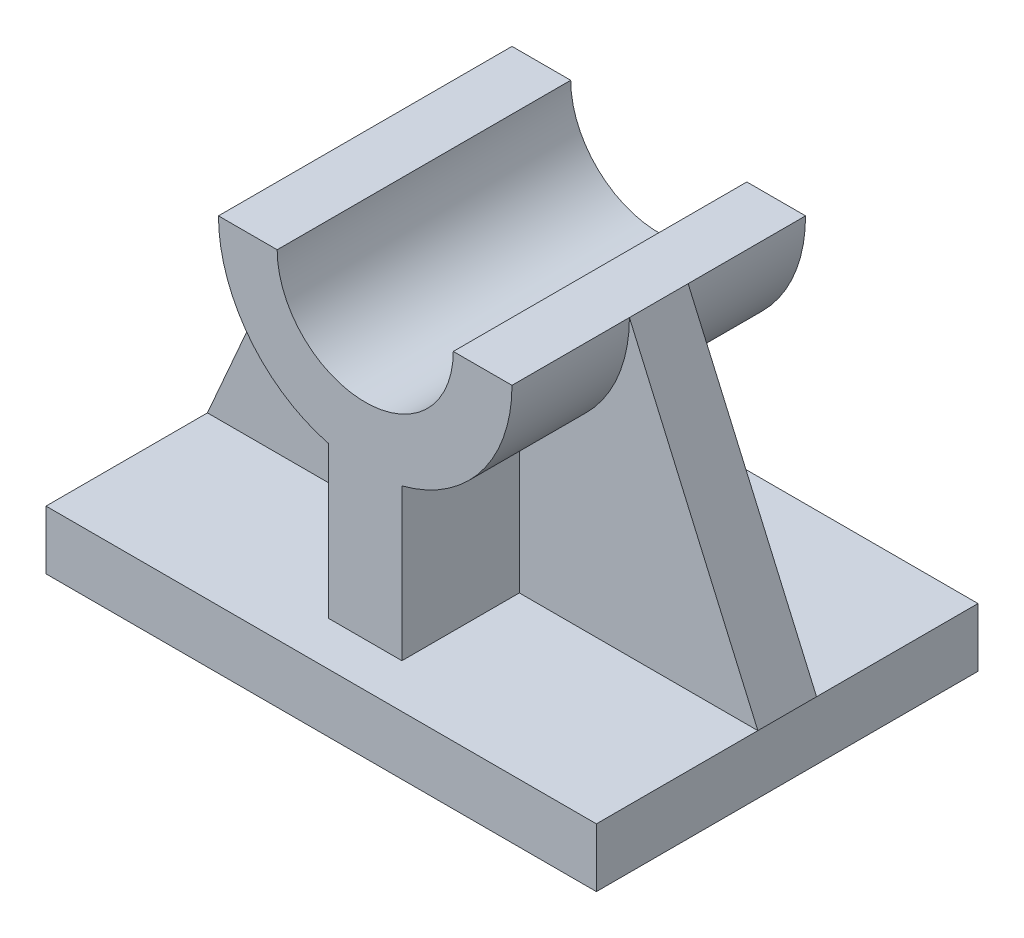
from build123d import *

# Parameters (mm, degrees)
BOSS_EXTRUDE1_DEPTH = 26
BOSS_EXTRUDE2_DEPTH = 20
RIB1_REACH          = 65.39
SKETCH6_WALL_W      = 172.439958848
SKETCH6_WALL_H      = 8
RIB2_REACH          = 65.39
SKETCH7_WALL_W      = 172.439958848
SKETCH7_WALL_H      = 8


with BuildPart() as part:
    # Sketch2 → Boss-Extrude1 (new, symmetric)
    with BuildSketch(Plane.XY):
        Polygon((-5, 4), (37.5, 4), (37.5, -4), (-37.5, -4), (-37.5, 4), align=None)
    extrude(amount=BOSS_EXTRUDE1_DEPTH, both=True)

    # Sketch2_3 → Boss-Extrude2 (add, symmetric)
    with BuildSketch(Plane.XY):
        with BuildLine():
            Line((-5, 24.635083269), (-5, 4))
            Line((-5, 4), (5, 4))
            Line((5, 4), (5, 24.635083269))
            ThreePointArc((5, 24.635083269), (15.811388301, 31.752551286), (20, 44))
            Line((20, 44), (12, 44))
            ThreePointArc((12, 44), (0, 32), (-12, 44))
            Line((-12, 44), (-20, 44))
            ThreePointArc((-20, 44), (-15.811388301, 31.752551286), (-5, 24.635083269))
        make_face()
    extrude(amount=BOSS_EXTRUDE2_DEPTH, both=True)

    # Sketch6 wall → Rib1 (add, up to next)
    with BuildSketch(Plane(origin=(28.75, 24, 0), x_dir=(0.40081883402, -0.916157334902, 0), z_dir=(0.916157334902, 0.40081883402, 0)), mode=Mode.PRIVATE) as rib1_sk1:
        Rectangle(SKETCH6_WALL_W, SKETCH6_WALL_H)
    rib1_tool1 = extrude(rib1_sk1.sketch, amount=-RIB1_REACH, mode=Mode.PRIVATE) - part.part
    add(rib1_tool1.solids().sort_by_distance((28.75, 24, 0))[0])

    # Sketch7 wall → Rib2 (add, up to next)
    with BuildSketch(Plane(origin=(-28.75, 24, 0), x_dir=(-0.40081883402, -0.916157334902, 0), z_dir=(0.916157334902, -0.40081883402, 0)), mode=Mode.PRIVATE) as rib2_sk1:
        Rectangle(SKETCH7_WALL_W, SKETCH7_WALL_H)
    rib2_tool1 = extrude(rib2_sk1.sketch, amount=RIB2_REACH, mode=Mode.PRIVATE) - part.part
    add(rib2_tool1.solids().sort_by_distance((-28.75, 24, 0))[0])


solid = part.part
